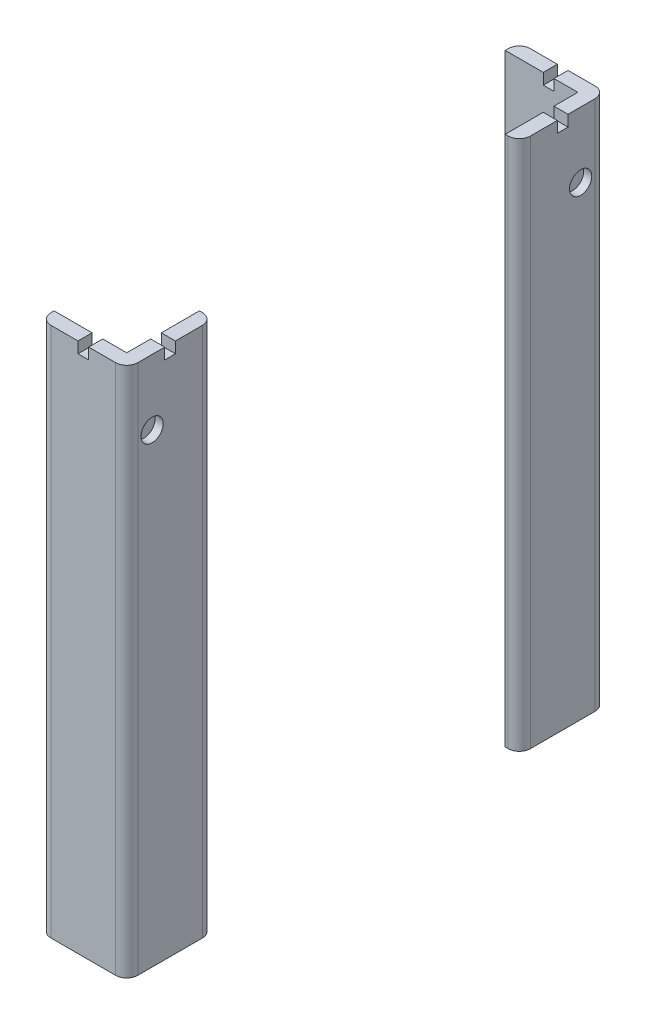
from build123d import *

# Parameters (mm, degrees)
SKETCH1_W                   = 32.730904613
SKETCH1_H                   = 237
BOSS_EXTRUDE1_DEPTH         = 6.35
SKETCH2_W                   = 39.08
SKETCH2_H                   = 237
BOSS_EXTRUDE3_DEPTH         = 6.35
SKETCH27_W                  = 4.8
SKETCH27_H                  = 5
LOCKING_MECHANISM_CUT_DEPTH = 6.35
SKETCH29_W                  = 39.08
SKETCH29_H                  = 1
F_1_MM_SPLIT_DEPTH          = 39.080905
SKETCH32_R                  = 5
LOCKING_MOUNT_DEPTH         = 6.35
SKETCH33_R                  = 1.9
M4_SCREW_HOLE_DEPTH         = 6.35
SKETCH34_R                  = 5
CUT_EXTRUDE1_DEPTH          = 10
SKETCH36_R                  = 5
CUT_EXTRUDE2_DEPTH          = 10
SKETCH40_W                  = 39.080904613
SKETCH40_H                  = 1
BOSS_EXTRUDE4_DEPTH         = 6.35
SKETCH41_W                  = 32.73
SKETCH41_H                  = 1
BOSS_EXTRUDE5_DEPTH         = 6.35
SKETCH42_W                  = 39.08
SKETCH42_H                  = 1
BOSS_EXTRUDE6_DEPTH         = 6.35
SKETCH43_W                  = 32.730904613
SKETCH43_H                  = 1
BOSS_EXTRUDE7_DEPTH         = 6.35
SKETCH44_W                  = 38.268421488
SKETCH44_H                  = 2
BOSS_EXTRUDE8_DEPTH         = 6.35
SKETCH45_W                  = 32.730904613
SKETCH45_H                  = 2
BOSS_EXTRUDE9_DEPTH         = 6.35
FILLET4_R                   = 5
SKETCH46_W                  = 39.08
SKETCH46_H                  = 2
BOSS_EXTRUDE10_DEPTH        = 6.35
SKETCH47_W                  = 32.730904613
SKETCH47_H                  = 2
BOSS_EXTRUDE11_DEPTH        = 6.35
FILLET5_R                   = 5


with BuildPart() as part:
    # Sketch1 → Boss-Extrude1 (new body)
    with BuildSketch(Plane.XY):
        with Locations((-16.365452306, 118.5)):
            Rectangle(SKETCH1_W, SKETCH1_H)
    extrude(amount=BOSS_EXTRUDE1_DEPTH)

    # Sketch2 → Boss-Extrude3 (add)
    with BuildSketch(Plane(origin=(0, 0, 0), x_dir=(0, 0, -1), z_dir=(1, 0, 0))):
        with Locations((13.19, 118.5)):
            Rectangle(SKETCH2_W, SKETCH2_H)
    extrude(amount=BOSS_EXTRUDE3_DEPTH)

    # Sketch27 → Locking_Mechanism_Cut (cut)
    with BuildSketch(Plane(origin=(6.35, 0, 0), x_dir=(0, 0, -1), z_dir=(1, 0, 0))):
        with Locations((13.180415796, 234.5)):
            Rectangle(SKETCH27_W, SKETCH27_H)
    locking_mechanism_cut = extrude(amount=-LOCKING_MECHANISM_CUT_DEPTH, mode=Mode.SUBTRACT)

    # Sketch29 → 1 mm split (cut)
    with BuildSketch(Plane(origin=(6.35, 0, 0), x_dir=(0, 0, -1), z_dir=(1, 0, 0))):
        with Locations((13.19, 109.586886099)):
            Rectangle(SKETCH29_W, SKETCH29_H)
    extrude(amount=-F_1_MM_SPLIT_DEPTH, mode=Mode.SUBTRACT)

    # LockingMechanismMirror: Locking_Mechanism_Cut across plane
    add(locking_mechanism_cut.mirror(Plane(origin=(0, 0, 0), x_dir=(0.707106781, 0, 0.707106781), z_dir=(0.707106781, 0, -0.707106781))), mode=Mode.SUBTRACT)


with BuildPart() as body_2:
    # Sketch32 → Locking Mount (new body)
    with BuildSketch(Plane(origin=(6.35, 0, 0), x_dir=(0, 0, -1), z_dir=(1, 0, 0))):
        with Locations((5.08, 207.536)):
            Circle(SKETCH32_R)
    extrude(amount=LOCKING_MOUNT_DEPTH)

    # Sketch33 → M4 Screw Hole (cut)
    with BuildSketch(Plane(origin=(12.7, 0, 0), x_dir=(0, 0, -1), z_dir=(1, 0, 0))):
        with Locations((5.08, 207.536)):
            Circle(SKETCH33_R)
    extrude(amount=-M4_SCREW_HOLE_DEPTH, mode=Mode.SUBTRACT)


with BuildPart() as body_3:
    # Mirror2: mirrored copy
    add(part.part.mirror(Plane(origin=(0, 0, -101.6), x_dir=(1, 0, 0), z_dir=(0, 0, -1))))


with BuildPart() as body_4:
    # Mirror2 2: mirrored copy
    add(body_2.part.mirror(Plane(origin=(0, 0, -101.6), x_dir=(1, 0, 0), z_dir=(0, 0, -1))))


with BuildPart() as cut_extrude1_tool:
    # Sketch34 → Cut-Extrude1 (new body)
    with BuildSketch(Plane(origin=(12.7, 0, 0), x_dir=(0, 0, -1), z_dir=(1, 0, 0))):
        with Locations((5.08, 207.536)):
            Circle(SKETCH34_R)
    extrude(amount=-CUT_EXTRUDE1_DEPTH)


with BuildPart() as part_1:
    add(part.part)

    # Cut-Extrude1: cut by cut_extrude1_tool
    add(cut_extrude1_tool.part, mode=Mode.SUBTRACT)

    # Sketch42 → Boss-Extrude6 (add)
    with BuildSketch(Plane(origin=(6.35, 0, 0), x_dir=(0, 0, -1), z_dir=(1, 0, 0))):
        with Locations((13.19, 109.586886099)):
            Rectangle(SKETCH42_W, SKETCH42_H)
    extrude(amount=-BOSS_EXTRUDE6_DEPTH)

    # Sketch43 → Boss-Extrude7 (add)
    with BuildSketch(Plane.XY.offset(6.35)):
        with Locations((-16.365452306, 109.586886099)):
            Rectangle(SKETCH43_W, SKETCH43_H)
    extrude(amount=-BOSS_EXTRUDE7_DEPTH)

    # Sketch44 → Boss-Extrude8 (add)
    with BuildSketch(Plane(origin=(6.35, 0, 0), x_dir=(0, 0, -1), z_dir=(1, 0, 0))):
        with Locations((12.784210744, -1)):
            Rectangle(SKETCH44_W, SKETCH44_H)
    extrude(amount=-BOSS_EXTRUDE8_DEPTH)

    # Sketch45 → Boss-Extrude9 (add)
    with BuildSketch(Plane.XY.offset(6.35)):
        with Locations((-16.365452306, -1)):
            Rectangle(SKETCH45_W, SKETCH45_H)
    extrude(amount=-BOSS_EXTRUDE9_DEPTH)

    # Fillet4
    fillet4_edges = [part_1.edges().sort_by_distance(p)[0] for p in [
        (6.35, 118.5, -32.73),
        (-32.730904613, 117.5, 6.35),
        (6.35, 117.5, 6.35),
    ]]
    fillet(fillet4_edges, radius=FILLET4_R)


with BuildPart() as body_2_1:
    add(body_2.part)

    # Cut-Extrude1: cut by cut_extrude1_tool
    add(cut_extrude1_tool.part, mode=Mode.SUBTRACT)


with BuildPart() as cut_extrude2_tool:
    # Sketch36 → Cut-Extrude2 (new body)
    with BuildSketch(Plane(origin=(12.7, 0, 0), x_dir=(0, 0, -1), z_dir=(1, 0, 0))):
        with Locations((198.12, 207.536)):
            Circle(SKETCH36_R)
    extrude(amount=-CUT_EXTRUDE2_DEPTH)


with BuildPart() as body_3_1:
    add(body_3.part)

    # Cut-Extrude2: cut by cut_extrude2_tool
    add(cut_extrude2_tool.part, mode=Mode.SUBTRACT)

    # Sketch40 → Boss-Extrude4 (add)
    with BuildSketch(Plane(origin=(0, 0, -209.55), x_dir=(-1, 0, 0), z_dir=(0, 0, -1))):
        with Locations((13.190452306, 109.586886099)):
            Rectangle(SKETCH40_W, SKETCH40_H)
    extrude(amount=-BOSS_EXTRUDE4_DEPTH)

    # Sketch41 → Boss-Extrude5 (add)
    with BuildSketch(Plane(origin=(6.35, 0, 0), x_dir=(0, 0, -1), z_dir=(1, 0, 0))):
        with Locations((186.835, 109.586886099)):
            Rectangle(SKETCH41_W, SKETCH41_H)
    extrude(amount=-BOSS_EXTRUDE5_DEPTH)

    # Sketch46 → Boss-Extrude10 (add)
    with BuildSketch(Plane(origin=(6.35, 0, 0), x_dir=(0, 0, -1), z_dir=(1, 0, 0))):
        with Locations((190.01, -1)):
            Rectangle(SKETCH46_W, SKETCH46_H)
    extrude(amount=-BOSS_EXTRUDE10_DEPTH)

    # Sketch47 → Boss-Extrude11 (add)
    with BuildSketch(Plane(origin=(0, 0, -209.55), x_dir=(-1, 0, 0), z_dir=(0, 0, -1))):
        with Locations((16.365452306, -1)):
            Rectangle(SKETCH47_W, SKETCH47_H)
    extrude(amount=-BOSS_EXTRUDE11_DEPTH)

    # Fillet5
    fillet5_edges = [body_3_1.edges().sort_by_distance(p)[0] for p in [
        (6.35, 117.5, -170.47),
        (6.35, 117.5, -209.55),
        (-32.730904613, 117.5, -209.55),
    ]]
    fillet(fillet5_edges, radius=FILLET5_R)


with BuildPart() as body_4_1:
    add(body_4.part)

    # Cut-Extrude2: cut by cut_extrude2_tool
    add(cut_extrude2_tool.part, mode=Mode.SUBTRACT)


solid = Compound([part_1.part, body_3_1.part])
